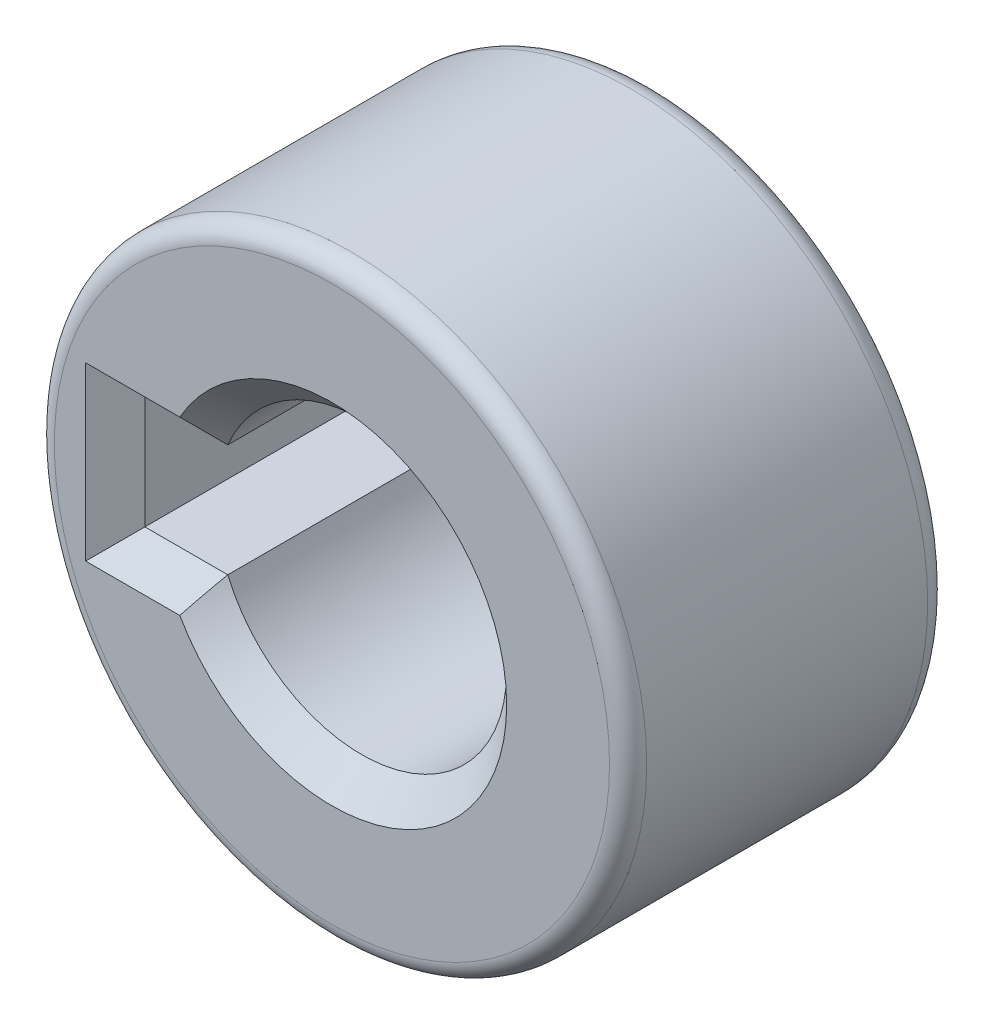
from build123d import *

# Parameters (mm, degrees)
SKETCH1_R               = 10
BOSS_EXTRUDE1_DEPTH     = 10.9
CUT_EXTRUDE1_DEPTH      = 10
CUT_EXTRUDE1_DEPTH_BACK = 10
CHAMFER1_SIZE           = 1
SCALE1_SCALE            = 0.75
SCALE2_SCALE            = 0.85
FILLET1_R               = 0.4
FILLET2_R               = 0.5


with BuildPart() as part:
    # Sketch1 → Boss-Extrude1 (new body)
    with BuildSketch(Plane(origin=(0, 0, 0), x_dir=(0, 1, 0), z_dir=(0, 0, 1))):
        Circle(SKETCH1_R)
    extrude(amount=BOSS_EXTRUDE1_DEPTH)

    # Sketch2 → Cut-Extrude1 (cut, two sides: drawn at the far end of the back side and taken through both)
    with BuildSketch(Plane.XY.offset(10.9).offset(-CUT_EXTRUDE1_DEPTH_BACK)):
        with BuildLine():
            Line((-4.516635916, 1.9), (-7.316635916, 1.9))
            Line((-7.316635916, 1.9), (-7.316635916, -1.9))
            Line((-7.316635916, -1.9), (-4.516635916, -1.9))
            ThreePointArc((-4.516635916, -1.9), (4.9, 0), (-4.516635916, 1.9))
        make_face()
    extrude(amount=CUT_EXTRUDE1_DEPTH + CUT_EXTRUDE1_DEPTH_BACK, mode=Mode.SUBTRACT)

    # Chamfer1
    chamfer1_edges = [part.edges().sort_by_distance(p)[0] for p in [
        (-5.916635916, -1.9, 10.9),
        (-7.316635916, 0, 10.9),
        (-5.916635916, 1.9, 10.9),
        (4.9, 0, 10.9),
    ]]
    chamfer(chamfer1_edges, length=CHAMFER1_SIZE)


with BuildPart() as part_1:
    # Scale1: scaled about (0.237766223, 0, 5.261412395)
    add(part.part.scale(SCALE1_SCALE).moved(Location((0.059441556, 0, 1.315353099))))


with BuildPart() as part_2:
    # Scale2: scaled about (0.237766223, 0, 5.261412395)
    add(part_1.part.scale(SCALE2_SCALE).moved(Location((0.035664933, 0, 0.789211859))))

    # Fillet1
    fillet1_edges = [part_2.edges().sort_by_distance(p)[0] for p in [
        (0.086190256, -6.375, 8.856011993),
    ]]
    fillet(fillet1_edges, radius=FILLET1_R)

    # Fillet2
    fillet2_edges = [part_2.edges().sort_by_distance(p)[0] for p in [
        (0.086190256, -6.375, 1.907261993),
    ]]
    fillet(fillet2_edges, radius=FILLET2_R)


solid = part_2.part
